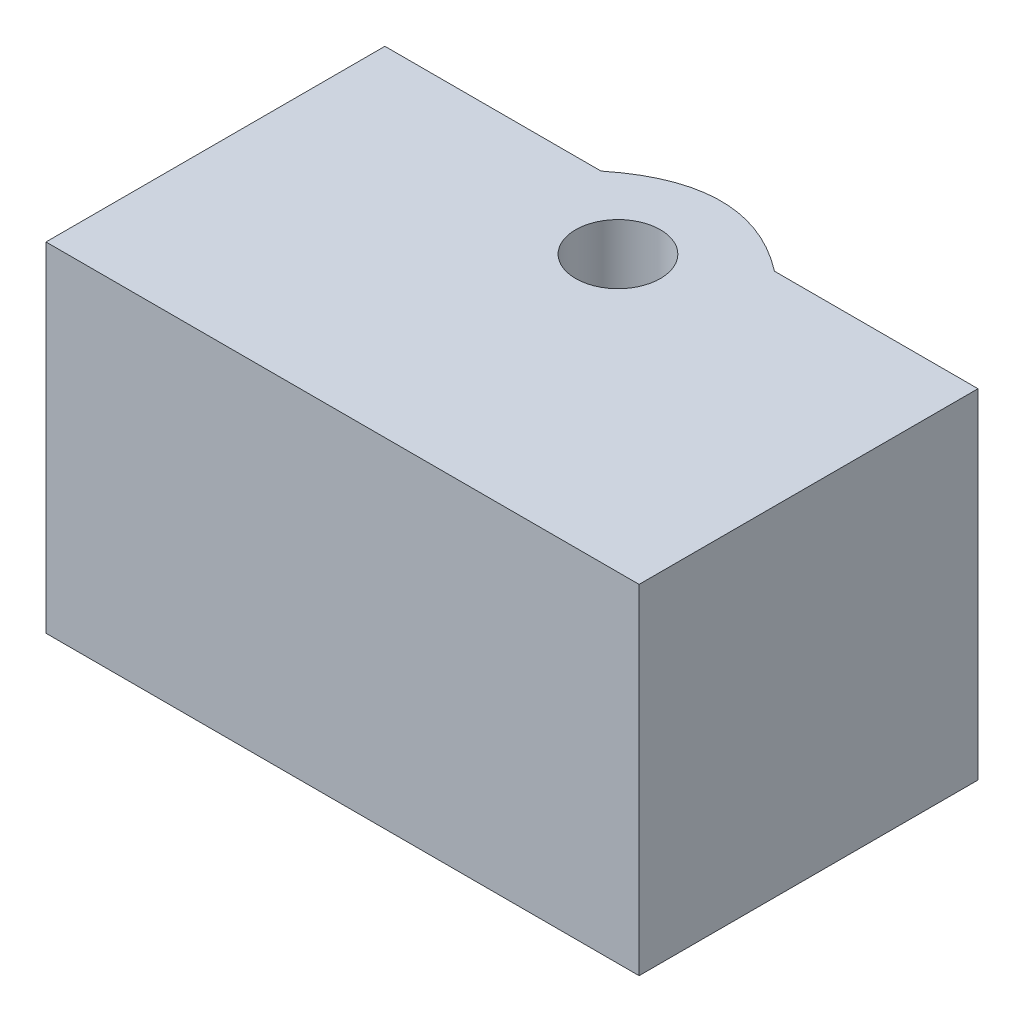
from build123d import *

# Parameters (mm, degrees)
SKETCH1_R           = 2.5
BOSS_EXTRUDE1_DEPTH = 20


with BuildPart() as part:
    # Sketch1 → Boss-Extrude1 (new body)
    with BuildSketch(Plane(origin=(0, 0, 0), x_dir=(1, 0, 0), z_dir=(0, 1, 0))):
        with BuildLine():
            Line((-16.572928834, 3.745367509), (-16.572928834, -16.254632491))
            Line((-16.572928834, -16.254632491), (18.427071166, -16.254632491))
            Line((18.427071166, -16.254632491), (18.427071166, 3.745367509))
            Line((18.427071166, 3.745367509), (6.415332466, 3.745367509))
            add(Edge.make_bspline(
                [(-3.819533202, 3.745367509), (1.198635577, 7.766174081), (6.415332466, 3.745367509)],
                knots=[0, 0, 0, 1, 1, 1], degree=2))
            Line((-3.819533202, 3.745367509), (-16.572928834, 3.745367509))
        make_face()
        with Locations((0.927071166, 0)):
            Circle(SKETCH1_R, mode=Mode.SUBTRACT)
    extrude(amount=BOSS_EXTRUDE1_DEPTH)


solid = part.part
